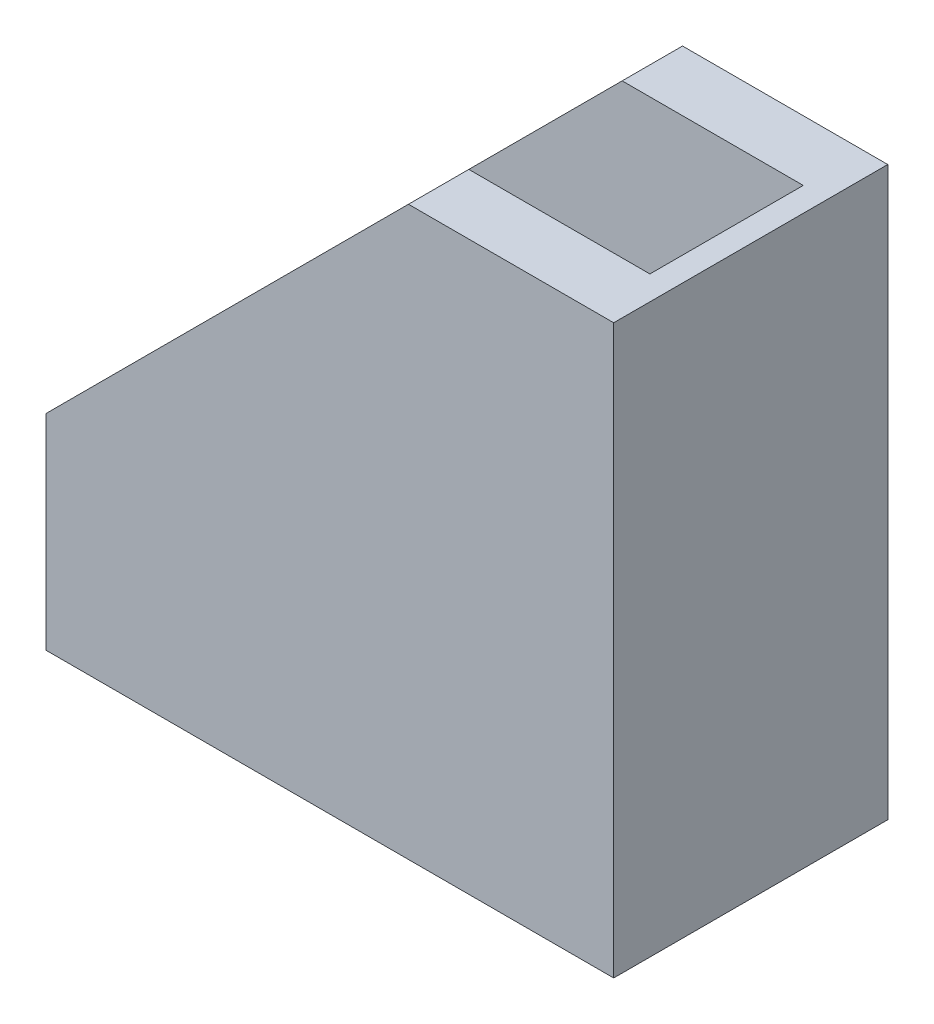
from build123d import *

# Parameters (mm, degrees)
BOSS_EXTRUDE1_DEPTH = 11.35
CUT_EXTRUDE1_DEPTH  = 6.35


with BuildPart() as part:
    # Sketch1 → Boss-Extrude1 (new body, symmetric)
    with BuildSketch(Plane.XY):
        Polygon((0, 0), (0, 47), (-17, 47), (-47, 17), (-47, 0), align=None)
    extrude(amount=BOSS_EXTRUDE1_DEPTH, both=True)

    # Sketch2 → Cut-Extrude1 (cut, symmetric)
    with BuildSketch(Plane.XY):
        Polygon((-47, 17), (-47, 2), (-2, 2), (-2, 47), (-17, 47), align=None)
    extrude(amount=CUT_EXTRUDE1_DEPTH, both=True, mode=Mode.SUBTRACT)


solid = part.part
